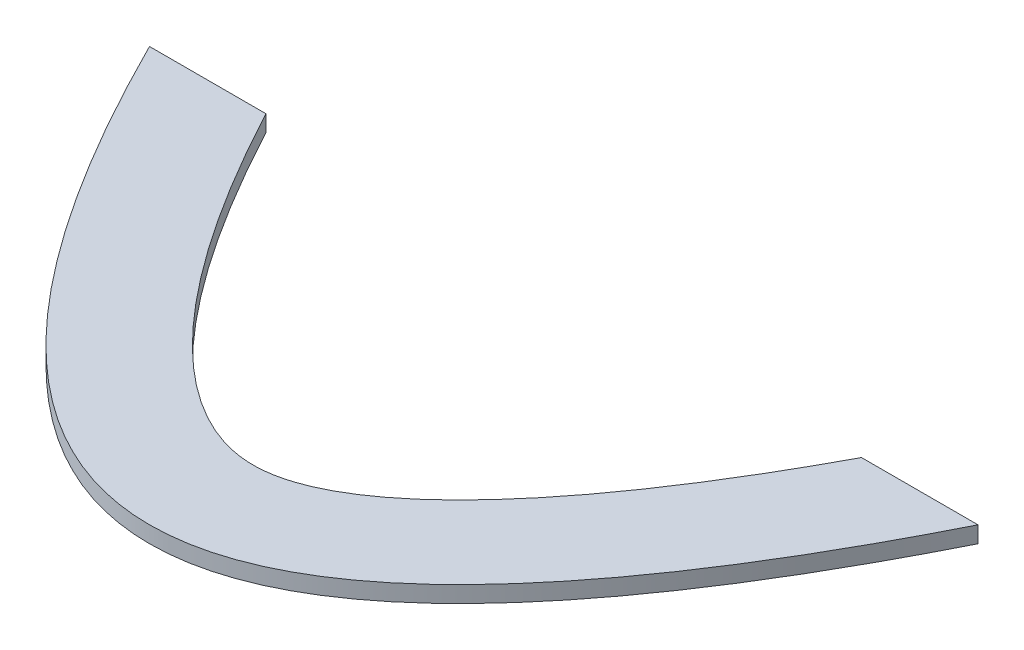
from build123d import *

# Parameters (mm, degrees)
BOSS_EXTRUDE2_DEPTH = 3.175


with BuildPart() as part:
    # Sketch2 → Boss-Extrude2 (new body)
    with BuildSketch(Plane(origin=(0, 0, 0), x_dir=(1, 0, 0), z_dir=(0, 1, 0))):
        with BuildLine():
            Line((-80, 80), (-57.499848226, 80))
            add(Edge.make_bspline(
                [(-57.499848226, 80), (-57.450870986, 79.907980251), (-56.611725313, 78.332936266), (-54.986650064, 75.336853958), (-51.848551558, 69.747324605), (-47.956843026, 63.181490269), (-43.346736628, 55.98023853), (-38.810175142, 49.461579158), (-32.88225187, 41.684871694), (-25.748214631, 33.686773229), (-17.845268417, 26.821229439), (-10.8707117, 22.528309012), (-5.006253324, 20.396797429), (0, 19.801601285), (5.006253324, 20.396797429), (10.8707117, 22.528309012), (17.845268418, 26.821229439), (25.748214631, 33.686773228), (32.88225187, 41.684871694), (38.810175142, 49.461579157), (43.346736628, 55.980238529), (47.956843026, 63.181490269), (51.848551558, 69.747324605), (54.986650064, 75.336853957), (56.611725313, 78.332936265), (57.450870986, 79.907980251), (57.499848227, 79.999999999)],
                knots=[0.082916819, 0.082916819, 0.082916819, 0.082916819, 0.083776621, 0.097650734, 0.111524847, 0.139273072, 0.167021297, 0.194769522, 0.222517748, 0.278014198, 0.333510649, 0.389007099, 0.44450355, 0.5, 0.55549645, 0.610992901, 0.666489351, 0.721985802, 0.777482252, 0.805230478, 0.832978703, 0.860726928, 0.888475153, 0.902349266, 0.916223379, 0.917083181, 0.917083181, 0.917083181, 0.917083181], degree=3))
            Line((57.499848227, 79.999999999), (80, 79.999999999))
            add(Edge.make_bspline(
                [(-80, 80), (0, -80), (80, 79.999999999)],
                knots=[0.056028396, 0.056028396, 0.056028396, 0.943971604, 0.943971604, 0.943971604], degree=2))
        make_face()
    extrude(amount=BOSS_EXTRUDE2_DEPTH)


solid = part.part
